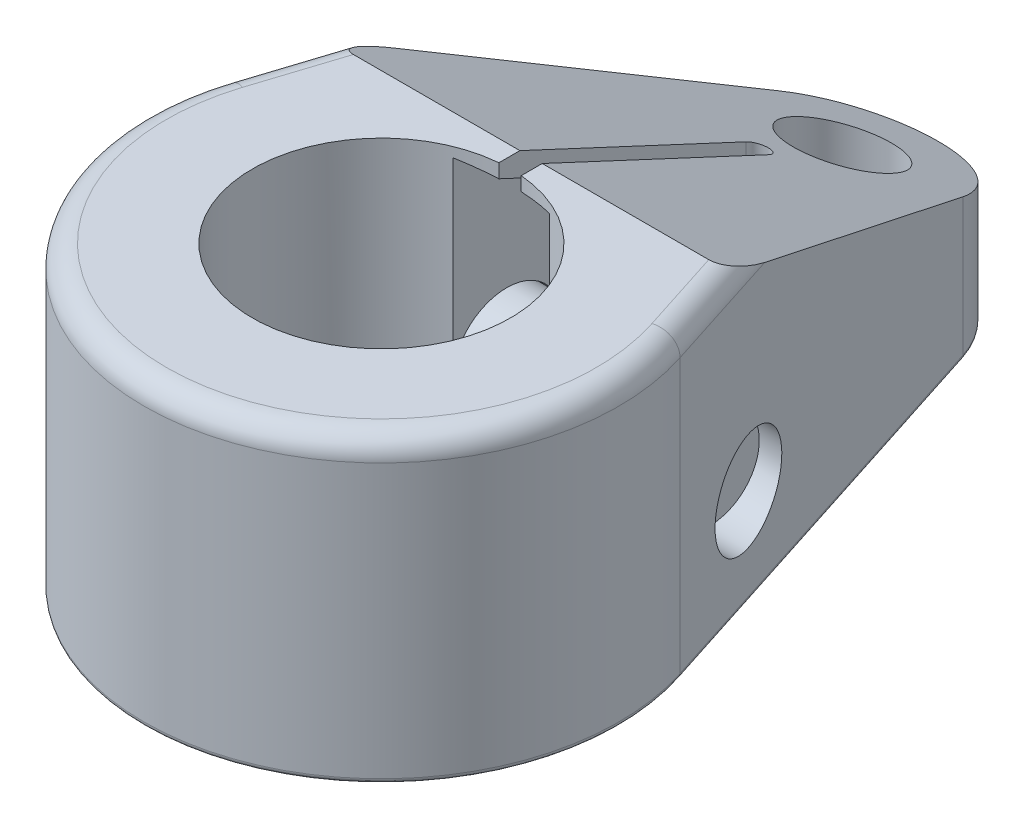
from build123d import *

# Parameters (mm, degrees)
SKETCH1_R                        = 19.06905
EXTRUDE1_DEPTH                   = 44.45
CUT_EXTRUDE1_DEPTH               = 36.052
CUT_EXTRUDE1_DEPTH_BACK          = 36.052
CUT_EXTRUDE2_REACH               = 49.625
CUT_EXTRUDE2_OFFSET_FROM_SURFACE = 3.175
CUT_EXTRUDE3_DEPTH               = 45.45
EXTRUDE2_DEPTH                   = 10.0076
SKETCH7_R                        = 8.001
EXTRUDE3_DEPTH                   = 48.387
SKETCH9_R                        = 7.2644
CUT_EXTRUDE4_DEPTH               = 45.4500001
FILLET1_R                        = 3.302
FILLET2_R                        = 0.762


with BuildPart() as part:
    # Sketch1 → Extrude1 (new body)
    with BuildSketch(Plane(origin=(0, 0, 0), x_dir=(1, 0, 0), z_dir=(0, 1, 0))):
        with BuildLine():
            Line((-13.540264262, 72.352796638), (-33.36707979, 10.736884572))
            ThreePointArc((-33.36707979, 10.736884572), (0, -35.052), (33.36707979, 10.736884572))
            Line((33.36707979, 10.736884572), (13.540264262, 72.352796638))
            ThreePointArc((13.540264262, 72.352796638), (0, 82.2198), (-13.540264262, 72.352796638))
        make_face()
        with Locations(Location((0, 0, 0), (0, 0, 270))):  # turned: the seam where the file's is
            Circle(SKETCH1_R, mode=Mode.SUBTRACT)
    extrude(amount=EXTRUDE1_DEPTH)

    # Sketch2 → Cut-Extrude1 (cut, two sides)
    with BuildSketch(Plane(origin=(0, 0, 0), x_dir=(0, 0, -1), z_dir=(1, 0, 0))) as cut_extrude1_sk:
        Polygon((22.098, 44.45), (82.2198, 16.414744238), (82.2198, 44.45), align=None)
    extrude(amount=CUT_EXTRUDE1_DEPTH, mode=Mode.SUBTRACT)
    extrude(cut_extrude1_sk.sketch, amount=-CUT_EXTRUDE1_DEPTH_BACK, mode=Mode.SUBTRACT)

    # Cut-Extrude2: up to this face of the body (flat: up to its plane, moved by the offset)
    cut_extrude2_end = Plane(part.part.faces().sort_by_distance((0, 32.9463195, -46.767722444))[0]).offset(-CUT_EXTRUDE2_OFFSET_FROM_SURFACE)
    # Sketch3 → Cut-Extrude2 (cut, up to the picked face)
    with BuildSketch(Plane.XZ, mode=Mode.PRIVATE) as cut_extrude2_sk1:
        with BuildLine():
            Line((-7.1374, -13.4874), (-7.1374, -50.0126))
            ThreePointArc((-7.1374, -50.0126), (0, -57.15), (7.1374, -50.0126))
            Line((7.1374, -50.0126), (7.1374, -13.4874))
            ThreePointArc((7.1374, -13.4874), (0, -6.35), (-7.1374, -13.4874))
        make_face()
    cut_extrude2_tool1 = split(extrude(cut_extrude2_sk1.sketch, amount=-CUT_EXTRUDE2_REACH, mode=Mode.PRIVATE), bisect_by=cut_extrude2_end, keep=Keep.BOTH, mode=Mode.PRIVATE)
    add(cut_extrude2_tool1.solids().sort_by(Axis((0, 0, -31.75), (0, 1, 0)))[0], mode=Mode.SUBTRACT)

    # Sketch4 → Cut-Extrude3 (cut, through all)
    with BuildSketch(Plane.XZ):
        with BuildLine():
            Line((-1.651, 0), (-1.651, -55.499))
            ThreePointArc((-1.651, -55.499), (0, -57.15), (1.651, -55.499))
            Line((1.651, -55.499), (1.651, 0))
            Line((1.651, 0), (-1.651, 0))
        make_face()
    extrude(amount=-CUT_EXTRUDE3_DEPTH, mode=Mode.SUBTRACT)

    # Sketch5 → Cut-Revolve1 (revolve, cut)
    with BuildSketch(Plane.XY.offset(-25.629), mode=Mode.PRIVATE) as cut_revolve1_sk:
        Polygon((-35.052, 31.7373), (-25.4762, 31.7373), (-25.4762, 22.4028), (7.1374, 22.4028), (7.1374, 21.5392), (35.052, 21.5392), (35.052, 14.2748), (-35.052, 14.2748), align=None)
    revolve(cut_revolve1_sk.sketch.rotate(Axis((-30.107344341, 14.2748, -25.629), (1, 0, 0)), 90), axis=Axis((-30.107344341, 14.2748, -25.629), (1, 0, 0)), mode=Mode.SUBTRACT)  # turned: the seam where the file's is

    # Sketch6 → Extrude2 (add)
    with BuildSketch(Plane.ZY.offset(25.4762)):
        Polygon((-11.770861489, 14.2748), (-18.699930744, 26.2763), (-32.558069256, 26.2763), (-39.487138511, 14.2748), (-32.558069256, 2.2733), (-18.699930744, 2.2733), align=None)
    extrude(amount=EXTRUDE2_DEPTH)

    # Sketch7 → Extrude3 (add)
    with BuildSketch(Plane.ZY.offset(25.4762)):
        with Locations(Location((-25.629, 14.2748, 0), (0, 0, 6.717974343))):  # turned: the seam where the file's is
            Circle(SKETCH7_R)
    extrude(amount=-EXTRUDE3_DEPTH)

    # Sketch8 → Cut-Revolve2 (revolve, cut)
    with BuildSketch(Plane.XY.offset(-25.629), mode=Mode.PRIVATE) as cut_revolve2_sk:
        Polygon((-35.4838, 2.2733), (-35.4838, -0.9017), (-33.650712895, -0.9017), align=None)
    revolve(cut_revolve2_sk.sketch.rotate(Axis((-5.551302264, 14.2748, -25.629), (-1, 0, 0)), 96.717974343), axis=Axis((-5.551302264, 14.2748, -25.629), (-1, 0, 0)), mode=Mode.SUBTRACT)  # turned: the seam where the file's is

    # Sketch9 → Cut-Extrude4 (cut, through all)
    with BuildSketch(Plane.XZ):
        with Locations(Location((0, -68.072, 0), (0, 0, 270))):  # turned: the seam where the file's is
            Circle(SKETCH9_R)
    extrude(amount=-CUT_EXTRUDE4_DEPTH, mode=Mode.SUBTRACT)

    # Fillet1
    fillet1_edges = [part.edges().sort_by_distance(p)[0] for p in [
        (0, 44.45, 35.052),
        (31.539185564, 44.45, -16.417442286),
        (-31.539185564, 44.45, -16.417442286),
    ]]
    fillet(fillet1_edges, radius=FILLET1_R)

    # Fillet2
    fillet2_edges = [part.edges().sort_by_distance(p)[0] for p in [
        (-32.589362108, 0, -13.153802419),
        (0, 0, 35.052),
        (23.453672026, 0, -41.544840605),
        (0, 0, -82.2198),
        (-19.508232131, 0, -53.806107539),
    ]]
    fillet(fillet2_edges, radius=FILLET2_R)


solid = part.part
